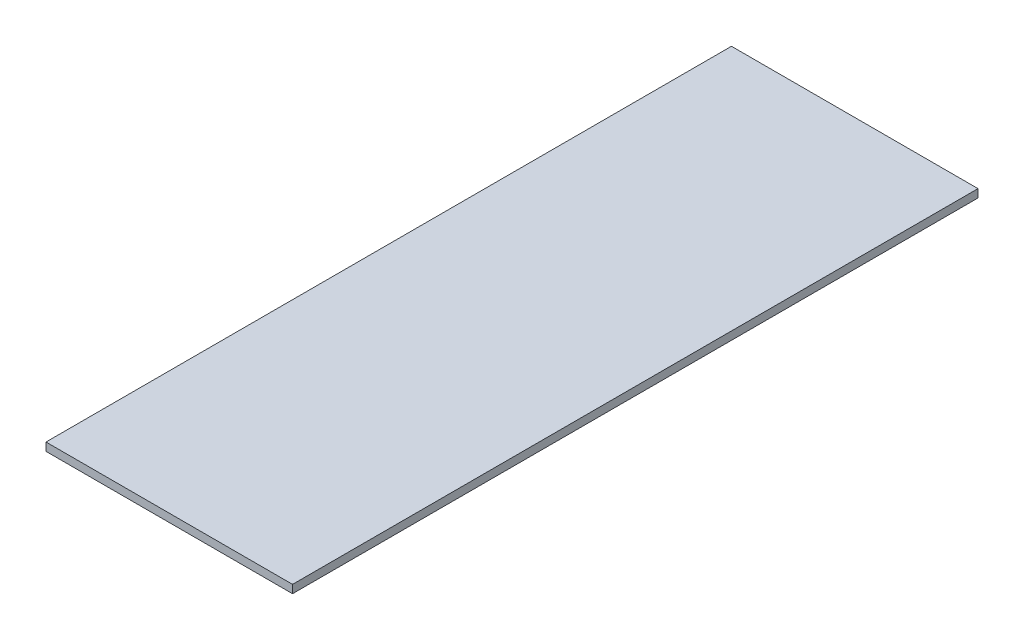
from build123d import *

# Parameters (mm, degrees)
SKETCH1_W           = 91
SKETCH1_H           = 226
BOSS_EXTRUDE1_DEPTH = 3
MOVE_FACE1_BY       = 27


with BuildPart() as part:
    # Sketch1 → Boss-Extrude1 (new body)
    with BuildSketch(Plane(origin=(0, 0, 0), x_dir=(1, 0, 0), z_dir=(0, 1, 0))):
        Rectangle(SKETCH1_W, SKETCH1_H)
    extrude(amount=BOSS_EXTRUDE1_DEPTH)

    # Move Face1: a face moved outward by 27.0
    extrude(part.faces().sort_by_distance((0, 1.5, 113))[0], amount=MOVE_FACE1_BY, dir=(0, 0, 1))


solid = part.part
